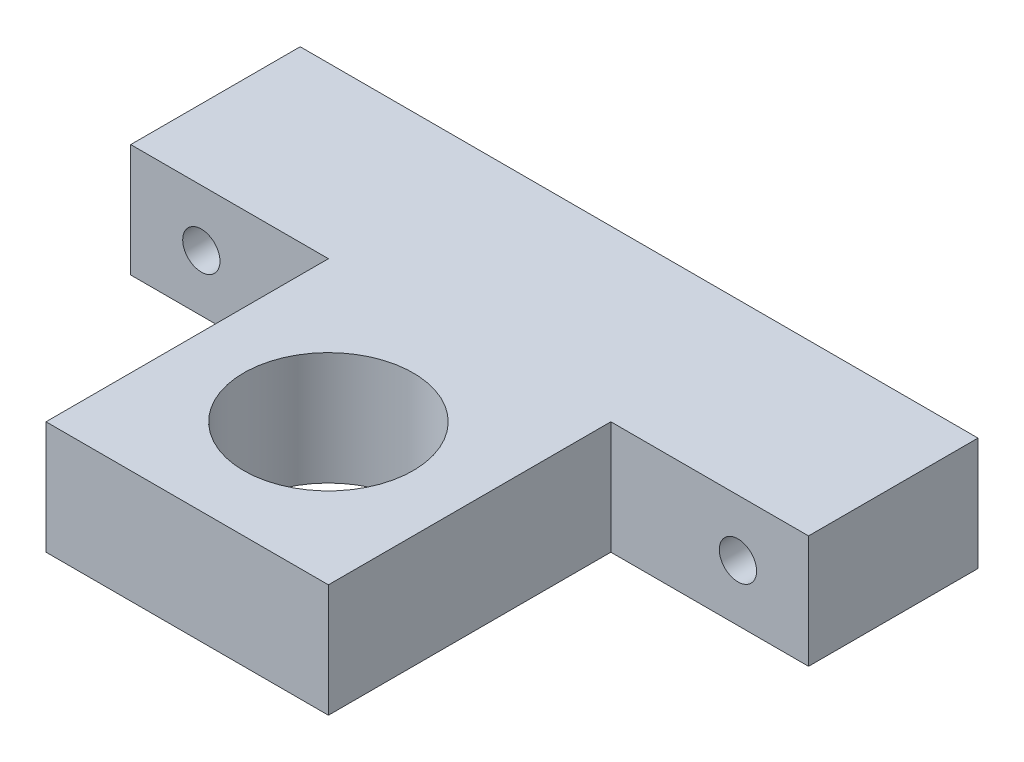
from build123d import *

# Parameters (mm, degrees)
SKETCH_2_R         = 7.5
EXTRUDE_1_DEPTH    = 5
HOLE_WIZARD_M4_1_D = 3.3


with BuildPart() as part:
    # 草圖2 → 填料-伸長1 (new body, symmetric)
    with BuildSketch(Plane(origin=(0, 0, 0), x_dir=(1, 0, 0), z_dir=(0, 1, 0))):
        Polygon((-12.5, -40), (-12.5, -15), (-30, -15), (-30, 0), (30, 0), (30, -15), (12.5, -15), (12.5, -40), align=None)
        with Locations((0, -27.5)):
            Circle(SKETCH_2_R, mode=Mode.SUBTRACT)
    extrude(amount=EXTRUDE_1_DEPTH, both=True)

    # M4 螺紋孔1 (through all)
    with Locations(Plane(origin=(0, 0, 0), x_dir=(-1, 0, 0), z_dir=(0, 0, -1))):
        with Locations((-23.75, 0), (23.75, 0)):
            Hole(HOLE_WIZARD_M4_1_D / 2)


solid = part.part
